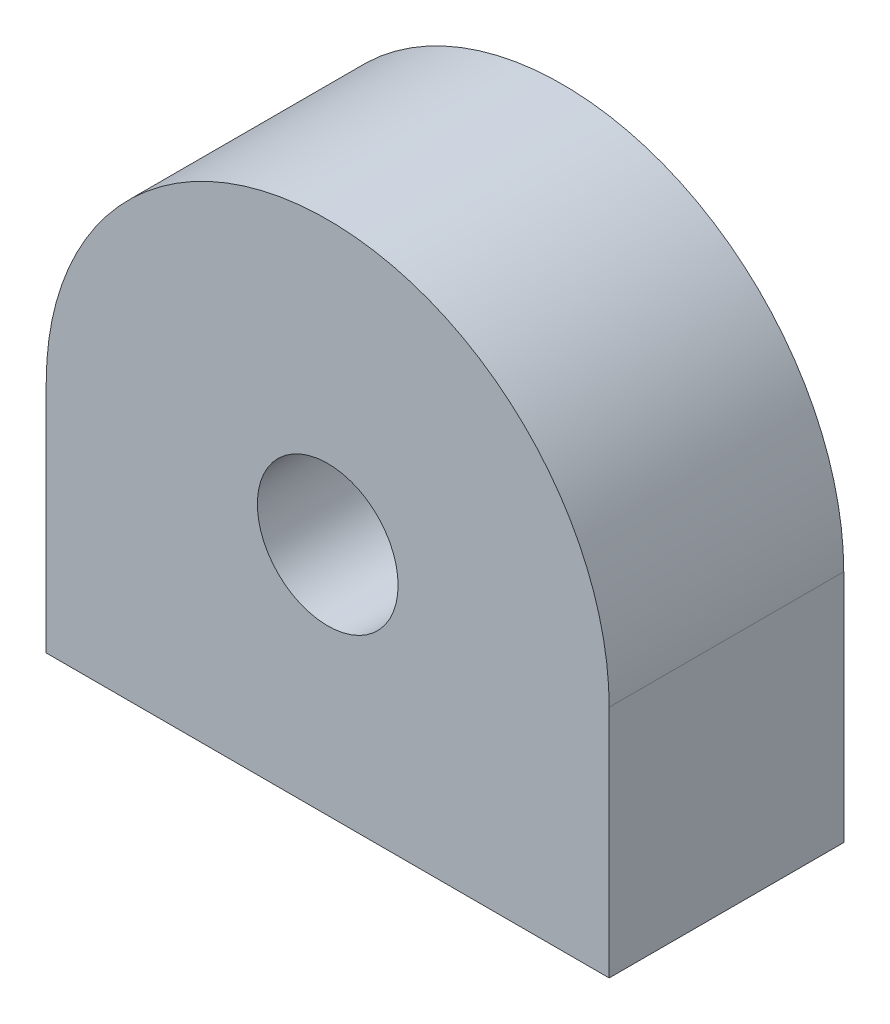
from build123d import *

# Parameters (mm, degrees)
BOSS_EXTRUDE1_DEPTH     = 2.5
SKETCH4_R               = 1.5
CUT_EXTRUDE1_DEPTH      = 3.5
CUT_EXTRUDE1_DEPTH_BACK = 3.5


with BuildPart() as part:
    # Sketch2 → Boss-Extrude1 (new body, symmetric)
    with BuildSketch(Plane.XY):
        with BuildLine():
            Line((-6, 0), (-6, -5))
            Line((-6, -5), (6, -5))
            Line((6, -5), (6, 0))
            ThreePointArc((6, 0), (0, 6), (-6, 0))
        make_face()
    extrude(amount=BOSS_EXTRUDE1_DEPTH, both=True)

    # Sketch4 → Cut-Extrude1 (cut, two sides)
    with BuildSketch(Plane.XY) as cut_extrude1_sk:
        Circle(SKETCH4_R)
    extrude(amount=CUT_EXTRUDE1_DEPTH, mode=Mode.SUBTRACT)
    extrude(cut_extrude1_sk.sketch, amount=-CUT_EXTRUDE1_DEPTH_BACK, mode=Mode.SUBTRACT)


solid = part.part
